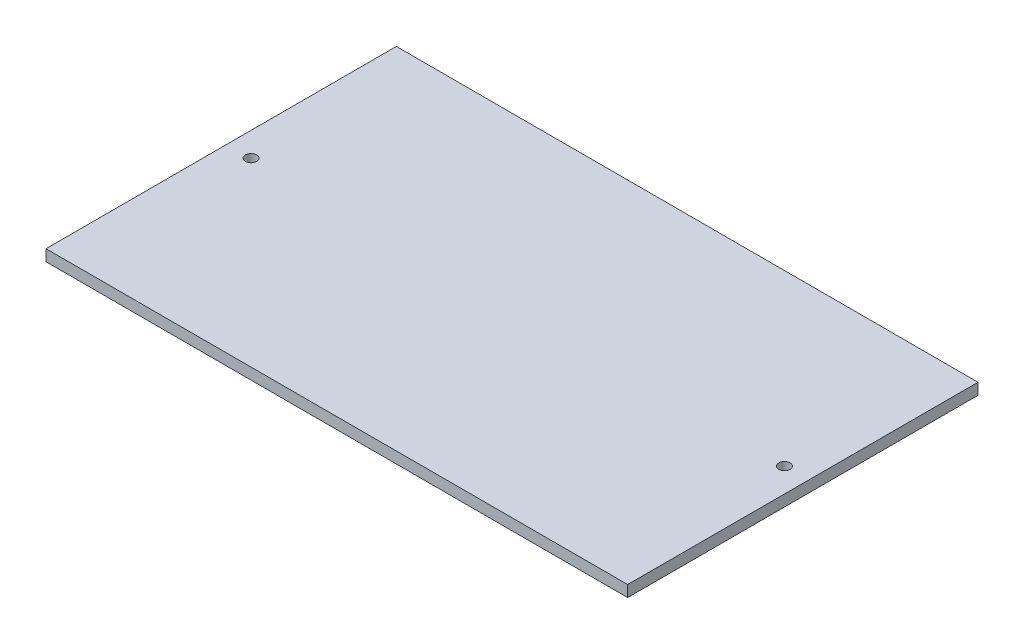
from build123d import *

# Parameters (mm, degrees)
SKETCH1_W           = 103
SKETCH1_H           = 62.04
SKETCH1_R           = 1
BOSS_EXTRUDE1_DEPTH = 2


with BuildPart() as part:
    # Sketch1 → Boss-Extrude1 (new body)
    with BuildSketch(Plane(origin=(0, 0, 0), x_dir=(1, 0, 0), z_dir=(0, 1, 0))):
        Rectangle(SKETCH1_W, SKETCH1_H)
        with Locations((47.23, 1.02)):
            Circle(SKETCH1_R, mode=Mode.SUBTRACT)
        with Locations((-47.23, 1.02)):
            Circle(SKETCH1_R, mode=Mode.SUBTRACT)
    extrude(amount=BOSS_EXTRUDE1_DEPTH)


solid = part.part
